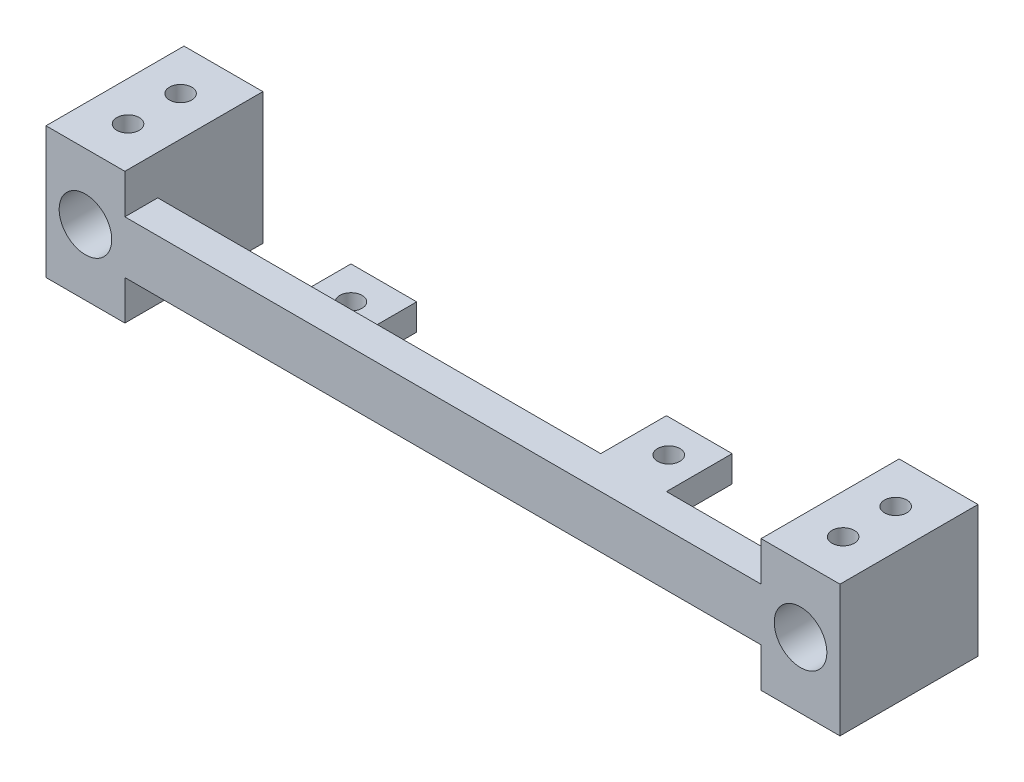
from build123d import *

# Parameters (mm, degrees)
ESQUISSE1_W             = 120.8
ESQUISSE1_H             = 8
BOSS_EXTRU_1_DEPTH      = 5
ESQUISSE2_W             = 10
ESQUISSE2_H             = 4
BOSS_EXTRU_2_DEPTH      = 10
ESQUISSE3_R             = 1.7
ENL_V_MAT_EXTRU_1_DEPTH = 10
ESQUISSE4_W             = 12
ESQUISSE4_H             = 20
BOSS_EXTRU_3_DEPTH      = 16
BOSS_EXTRU_3_DEPTH_BACK = 5
ESQUISSE5_R             = 4
ENL_V_MAT_EXTRU_2_DEPTH = 24
ESQUISSE6_R             = 1.7
ENL_V_MAT_EXTRU_3_DEPTH = 24


with BuildPart() as part:
    # Esquisse1 → Boss.-Extru.1 (new body)
    with BuildSketch(Plane.XY):
        Rectangle(ESQUISSE1_W, ESQUISSE1_H)
    extrude(amount=BOSS_EXTRU_1_DEPTH)

    # Esquisse2 → Boss.-Extru.2 (add)
    with BuildSketch(Plane(origin=(0, 0, 0), x_dir=(-1, 0, 0), z_dir=(0, 0, -1))):
        with Locations((24, -2)):
            Rectangle(ESQUISSE2_W, ESQUISSE2_H)
        with Locations((-24, 2)):
            Rectangle(ESQUISSE2_W, ESQUISSE2_H)
    extrude(amount=BOSS_EXTRU_2_DEPTH)

    # Esquisse3 → Enlèv. mat.-Extru.1 (cut)
    with BuildSketch(Plane(origin=(0, 4, 0), x_dir=(1, 0, 0), z_dir=(0, 1, 0))):
        with Locations((-24, 5)):
            Circle(ESQUISSE3_R)
        with Locations((24.35, 5)):
            Circle(ESQUISSE3_R)
    extrude(amount=-ENL_V_MAT_EXTRU_1_DEPTH, mode=Mode.SUBTRACT)

    # Esquisse4 → Boss.-Extru.3 (add, two sides)
    with BuildSketch(Plane(origin=(0, 0, 0), x_dir=(-1, 0, 0), z_dir=(0, 0, -1))) as boss_extru_3_sk:
        with Locations((54.4, 0)):
            Rectangle(ESQUISSE4_W, ESQUISSE4_H)
        with Locations((-54.4, 0)):
            Rectangle(ESQUISSE4_W, ESQUISSE4_H)
    extrude(amount=BOSS_EXTRU_3_DEPTH)
    extrude(boss_extru_3_sk.sketch, amount=-BOSS_EXTRU_3_DEPTH_BACK)

    # Esquisse5 → Enlèv. mat.-Extru.2 (cut)
    with BuildSketch(Plane(origin=(0, 0, -16), x_dir=(-1, 0, 0), z_dir=(0, 0, -1))):
        with Locations((54.4, 0)):
            Circle(ESQUISSE5_R)
        with Locations((-54.4, 0)):
            Circle(ESQUISSE5_R)
    extrude(amount=-ENL_V_MAT_EXTRU_2_DEPTH, mode=Mode.SUBTRACT)

    # Esquisse6 → Enlèv. mat.-Extru.3 (cut)
    with BuildSketch(Plane.XZ.offset(10)):
        with Locations((54.4, -9.479015636)):
            Circle(ESQUISSE6_R)
        with Locations((54.4, -1.479015636)):
            Circle(ESQUISSE6_R)
        with Locations((-54.4, -1.479015636)):
            Circle(ESQUISSE6_R)
        with Locations((-54.4, -9.479015636)):
            Circle(ESQUISSE6_R)
    extrude(amount=-ENL_V_MAT_EXTRU_3_DEPTH, mode=Mode.SUBTRACT)


solid = part.part
